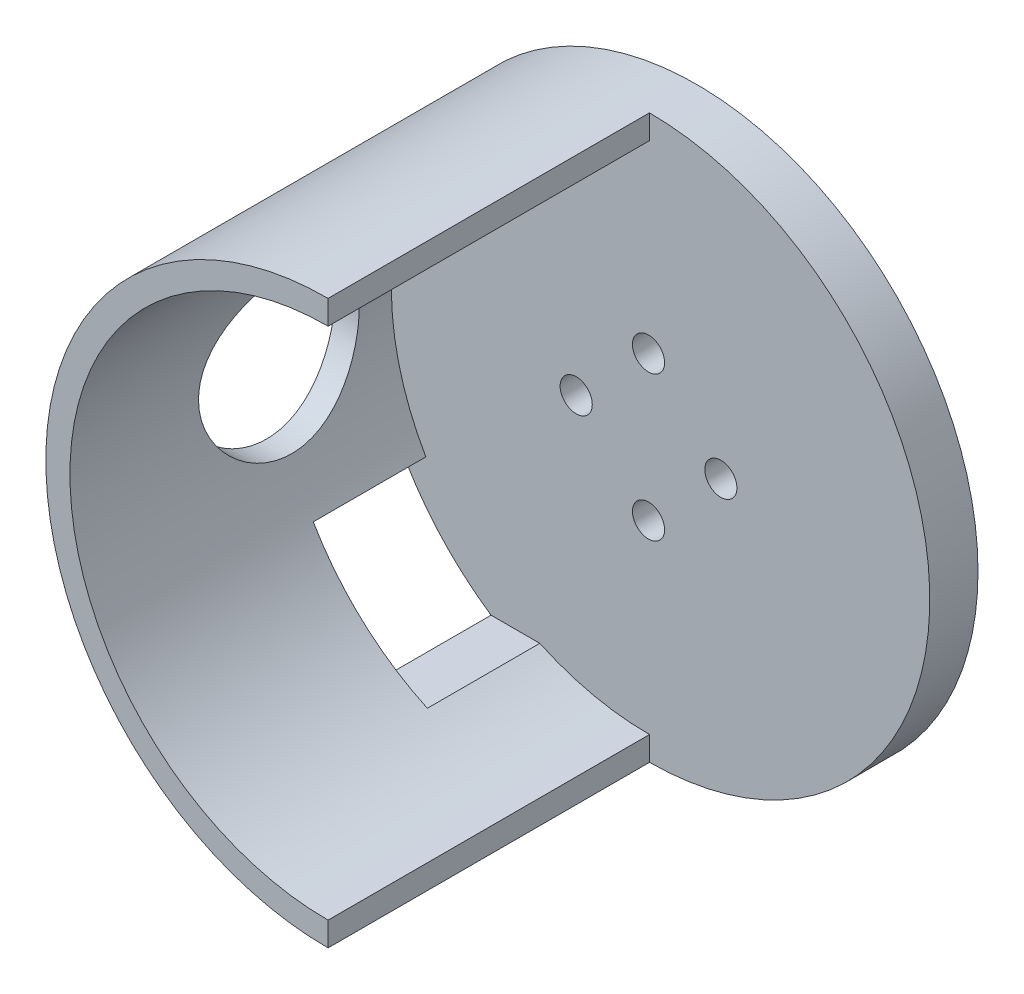
from build123d import *

# Parameters (mm, degrees)
SKIZZE3_R                       = 17.5
SKIZZE3_R_2                     = 16
AUFSATZ_LINEAR_AUSTRAGEN3_DEPTH = 20
SKIZZE4_R                       = 17.5
AUFSATZ_LINEAR_AUSTRAGEN4_DEPTH = 3
SKIZZE5_R                       = 5
SCHNITT_LINEAR_AUSTRAGEN1_DEPTH = 40
SKIZZE6_R                       = 1
SCHNITT_LINEAR_AUSTRAGEN2_DEPTH = 10
SKIZZE7_W                       = 31.87732214
SKIZZE7_H                       = 34.999785002
SCHNITT_LINEAR_AUSTRAGEN3_DEPTH = 30
SKIZZE8_W                       = 7
SKIZZE8_H                       = 6.5
SCHNITT_LINEAR_AUSTRAGEN4_DEPTH = 30


with BuildPart() as part:
    # Skizze3 → Aufsatz-Linear austragen3 (new body)
    with BuildSketch(Plane.XY):
        Circle(SKIZZE3_R)
        Circle(SKIZZE3_R_2, mode=Mode.SUBTRACT)
    extrude(amount=AUFSATZ_LINEAR_AUSTRAGEN3_DEPTH)

    # Skizze4 → Aufsatz-Linear austragen4 (add)
    with BuildSketch(Plane.XY):
        Circle(SKIZZE4_R)
    extrude(amount=-AUFSATZ_LINEAR_AUSTRAGEN4_DEPTH)

    # Skizze5 → Schnitt-Linear austragen1 (cut)
    with BuildSketch(Plane(origin=(0, 0, 0), x_dir=(0, 0, -1), z_dir=(1, 0, 0))):
        with Locations((-7, 0)):
            Circle(SKIZZE5_R)
    extrude(amount=-SCHNITT_LINEAR_AUSTRAGEN1_DEPTH, mode=Mode.SUBTRACT)

    # Skizze6 → Schnitt-Linear austragen2 (cut)
    with BuildSketch(Plane(origin=(0, 0, -3), x_dir=(-1, 0, 0), z_dir=(0, 0, -1))):
        with Locations((-4.5, 0)):
            Circle(SKIZZE6_R)
        with Locations((0, 4.5)):
            Circle(SKIZZE6_R)
        with Locations((4.5, 0)):
            Circle(SKIZZE6_R)
        with Locations((0, -4.5)):
            Circle(SKIZZE6_R)
    extrude(amount=-SCHNITT_LINEAR_AUSTRAGEN2_DEPTH, mode=Mode.SUBTRACT)

    # Skizze7 → Schnitt-Linear austragen3 (cut)
    with BuildSketch(Plane.XY):
        with Locations((16, 0)):
            Rectangle(SKIZZE7_W, SKIZZE7_H)
    extrude(amount=SCHNITT_LINEAR_AUSTRAGEN3_DEPTH, mode=Mode.SUBTRACT)

    # Skizze8 → Schnitt-Linear austragen4 (cut)
    with BuildSketch(Plane(origin=(0, 0, 0), x_dir=(0, 0, -1), z_dir=(1, 0, 0))):
        with Locations((-3.5, -11.25)):
            Rectangle(SKIZZE8_W, SKIZZE8_H)
    extrude(amount=-SCHNITT_LINEAR_AUSTRAGEN4_DEPTH, mode=Mode.SUBTRACT)


solid = part.part
